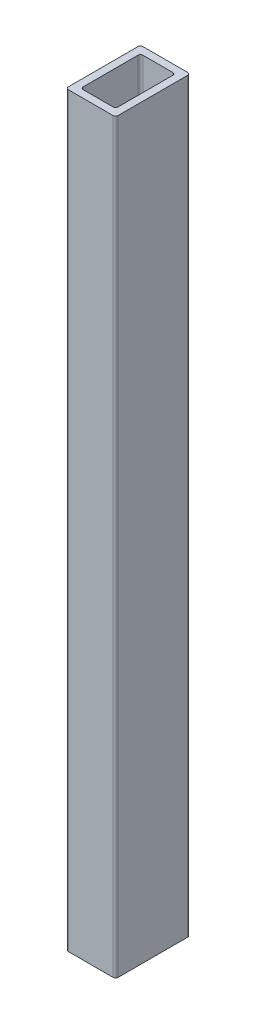
from build123d import *

# Parameters (mm, degrees)
BOSS_EXTRUDE1_DEPTH = 1500


with BuildPart() as part:
    # Sketch1 → Boss-Extrude1 (new body)
    with BuildSketch(Plane(origin=(0, 0, 0), x_dir=(1, 0, 0), z_dir=(0, 1, 0))):
        with BuildLine():
            Line((-45, -75), (45, -75))
            ThreePointArc((45, -75), (48.535533906, -73.535533906), (50, -70))
            Line((50, -70), (50, 70))
            ThreePointArc((50, 70), (48.535533906, 73.535533906), (45, 75))
            Line((45, 75), (-45, 75))
            ThreePointArc((-45, 75), (-48.535533906, 73.535533906), (-50, 70))
            Line((-50, 70), (-50, -70))
            ThreePointArc((-50, -70), (-48.535533906, -73.535533906), (-45, -75))
        make_face()
        with BuildLine():
            Line((-30, -60), (30, -60))
            ThreePointArc((30, -60), (33.535533906, -58.535533906), (35, -55))
            Line((35, -55), (35, 55))
            ThreePointArc((35, 55), (33.535533906, 58.535533906), (30, 60))
            Line((30, 60), (-30, 60))
            ThreePointArc((-30, 60), (-33.535533906, 58.535533906), (-35, 55))
            Line((-35, 55), (-35, -55))
            ThreePointArc((-35, -55), (-33.535533906, -58.535533906), (-30, -60))
        make_face(mode=Mode.SUBTRACT)
    extrude(amount=BOSS_EXTRUDE1_DEPTH)


solid = part.part
